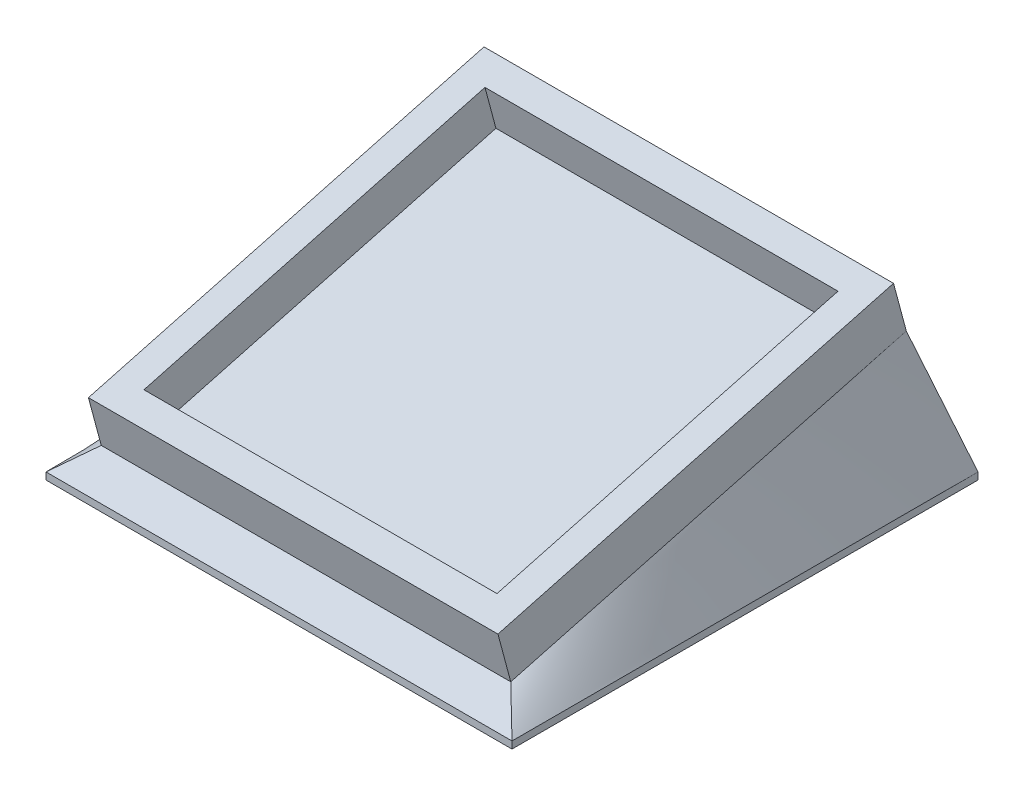
from build123d import *

# Parameters (mm, degrees)
SKETCH1_W             = 36.83
SKETCH1_H             = 36.83
BOSS_EXTRUDE1_DEPTH   = 0.635
SKETCH2_W             = 36.83
SKETCH2_H             = 36.83
SKETCH2_W_2           = 31.75
SKETCH2_H_2           = 31.75
BOSS_EXTRUDE2_DEPTH   = 3.81
SKETCH3_W             = 41.91
SKETCH3_H             = 41.91
BOSS_EXTRUDE3_DEPTH   = 0.635
BODY_MOVE_COPY2_ANGLE = 15
CUT_EXTRUDE1_DEPTH    = 0.635


with BuildPart() as part:
    # Sketch1 → Boss-Extrude1 (new body)
    with BuildSketch(Plane(origin=(0, 0, 0), x_dir=(1, 0, 0), z_dir=(0, 1, 0))):
        with Locations((-3.873751075, -5.413720286)):
            Rectangle(SKETCH1_W, SKETCH1_H)
    extrude(amount=BOSS_EXTRUDE1_DEPTH)

    # Sketch2 → Boss-Extrude2 (add)
    with BuildSketch(Plane(origin=(0, 0.635, 0), x_dir=(1, 0, 0), z_dir=(0, 1, 0))):
        with Locations((-3.873751075, -5.413720286)):
            Rectangle(SKETCH2_W, SKETCH2_H)
        with Locations((-3.873751075, -5.413720286)):
            Rectangle(SKETCH2_W_2, SKETCH2_H_2, mode=Mode.SUBTRACT)
    extrude(amount=BOSS_EXTRUDE2_DEPTH)


with BuildPart() as part_1:
    # Body-Move/Copy1: moved
    add(part.part.moved(Location((0, 7.62, 0))))


with BuildPart() as body_2:
    # Sketch3 → Boss-Extrude3 (new body)
    with BuildSketch(Plane(origin=(0, 0, 0), x_dir=(1, 0, 0), z_dir=(0, 1, 0))):
        with Locations((-3.873751075, -5.413720286)):
            Rectangle(SKETCH3_W, SKETCH3_H)
    extrude(amount=BOSS_EXTRUDE3_DEPTH)


with BuildPart() as part_2:
    # Body-Move/Copy2: moved
    add(part_1.part.rotate(Axis((0, 4.7625, 5.413720286), (1, 0, 0)), BODY_MOVE_COPY2_ANGLE))


    add(body_2.part)  # loft1 joins it to this body
    # loft from a face of the part (loft1)
    loft([part_2.faces().sort_by_distance((-3.873751075, 7.522633049, 6.153295707))[0], part_2.faces().sort_by_distance((-3.873751075, 0.635, 5.413720286))[0]])

    # Sketch4 → Cut-Extrude1 (cut)
    with BuildSketch(Plane(origin=(0, 4.748067122, -14.162331732), x_dir=(-1, 0, 0), z_dir=(0, 0.3178715830785106, -0.9481337757253253))):
        Polygon((-9.954307351, 4.241933762), (-9.307171934, 4.241933762), (-9.307171934, 0.741933762), (-9.621274498, 0.741933762), (-9.621274498, 3.882959403), (-10.159736037, 3.882959403), align=None)
        with BuildLine():
            Line((-5.807171934, 4.241933762), (-5.807171934, 3.882959403))
            Line((-5.807171934, 3.882959403), (-6.997676742, 3.882959403))
            Line((-6.997676742, 3.882959403), (-7.186278505, 2.962386486))
            add(Edge.make_bspline(
                [(-7.186278505, 2.962386486), (-7.14922263, 2.972616758), (-7.077432735, 2.992436292), (-6.971472874, 3.014442062), (-6.87088067, 3.027707506), (-6.8056053, 3.029518817), (-6.774018889, 3.0303953)],
                knots=[0, 0, 0, 0, 1.100273476, 2.13160584, 3.095893838, 4, 4, 4, 4], degree=3))
            add(Edge.make_bspline(
                [(-6.774018889, 3.0303953), (-6.73493515, 3.029549365), (-6.658086752, 3.027886044), (-6.545647805, 3.011914194), (-6.438314912, 2.98677428), (-6.336312542, 2.951653758), (-6.239451991, 2.906744025), (-6.14862443, 2.850644084), (-6.062466517, 2.785110753), (-5.982523923, 2.709765741), (-5.909999615, 2.626844124), (-5.846233625, 2.537686253), (-5.792071035, 2.443158591), (-5.74851028, 2.342357982), (-5.713725946, 2.236398829), (-5.690573951, 2.124166247), (-5.675157242, 2.006718126), (-5.673434856, 1.926413556), (-5.67255655, 1.885463409)],
                knots=[0, 0, 0, 0, 1.052922333, 2.070308379, 3.05430497, 4.020497103, 4.973039431, 5.925935799, 6.892292201, 7.88610001, 8.88166317, 9.857072816, 10.836096531, 11.812156883, 12.81219415, 13.836441305, 14.89672472, 16, 16, 16, 16], degree=3))
            add(Edge.make_bspline(
                [(-5.67255655, 1.885463409), (-5.673221625, 1.856941189), (-5.674542788, 1.800282201), (-5.681261375, 1.716138001), (-5.694197091, 1.633775168), (-5.711564815, 1.553182776), (-5.734107233, 1.474513403), (-5.761396287, 1.397541876), (-5.794792315, 1.322747269), (-5.83142369, 1.249421874), (-5.872670168, 1.179223367), (-5.918448675, 1.11357438), (-5.966814167, 1.051490099), (-6.018855552, 0.993636366), (-6.075056547, 0.940393348), (-6.134736514, 0.891445066), (-6.197419233, 0.845963736), (-6.264074475, 0.805795541), (-6.333216958, 0.768832585), (-6.405845176, 0.738509047), (-6.480305876, 0.711398519), (-6.557670752, 0.689788992), (-6.637764564, 0.672856437), (-6.72071934, 0.661355836), (-6.80610001, 0.652979399), (-6.863975022, 0.652455042), (-6.893209595, 0.652190172)],
                knots=[0, 0, 0, 0, 1.056347294, 2.098418968, 3.122841568, 4.141288669, 5.149314143, 6.15115421, 7.162517403, 8.180376062, 9.185164535, 10.17417709, 11.141909838, 12.097768115, 13.052685741, 14.0056014, 14.954263652, 15.917497458, 16.885230207, 17.854509472, 18.828990115, 19.81800267, 20.826176721, 21.857883937, 22.917946725, 24, 24, 24, 24], degree=3))
            add(Edge.make_bspline(
                [(-6.893209595, 0.652190172), (-6.928083775, 0.65288101), (-6.996694606, 0.654240152), (-7.097215173, 0.668458637), (-7.193929779, 0.688822554), (-7.28605988, 0.719458824), (-7.374431144, 0.757846118), (-7.457853861, 0.80636229), (-7.538459637, 0.861341394), (-7.612971674, 0.926221747), (-7.682127788, 0.997137429), (-7.744034297, 1.07409507), (-7.799167873, 1.155824512), (-7.84664562, 1.242722666), (-7.887143642, 1.334561197), (-7.91895863, 1.431684198), (-7.944636985, 1.533584202), (-7.955500405, 1.603737712), (-7.961018088, 1.639369659)],
                knots=[0, 0, 0, 0, 1.0467383, 2.05933395, 3.04377827, 4.011590433, 4.970194871, 5.932262533, 6.905835911, 7.896367577, 8.894135286, 9.877477877, 10.858688626, 11.851381753, 12.8477658, 13.868841284, 14.917554742, 16, 16, 16, 16], degree=3))
            Line((-7.961018088, 1.639369659), (-7.646915524, 1.639369659))
            add(Edge.make_bspline(
                [(-7.646915524, 1.639369659), (-7.639186967, 1.605993207), (-7.62433225, 1.541841812), (-7.591726502, 1.451710471), (-7.551860626, 1.371391247), (-7.504456278, 1.299821664), (-7.447906247, 1.237412666), (-7.383376818, 1.181795604), (-7.311029095, 1.131620475), (-7.230635865, 1.089797708), (-7.145822786, 1.054128954), (-7.057055576, 1.03037726), (-6.96675123, 1.013676367), (-6.905672859, 1.012004606), (-6.874980428, 1.011164531)],
                knots=[0, 0, 0, 0, 1.136247022, 2.183929868, 3.172523383, 4.106158343, 5.02341133, 5.958108904, 6.928429099, 7.938127109, 8.96079061, 9.975095812, 10.982467395, 12, 12, 12, 12], degree=3))
            add(Edge.make_bspline(
                [(-6.874980428, 1.011164531), (-6.845021984, 1.011985309), (-6.786033561, 1.013601427), (-6.699222175, 1.026040439), (-6.6154093, 1.045198011), (-6.535421944, 1.073867866), (-6.457860404, 1.108712584), (-6.384686634, 1.15342766), (-6.313783757, 1.204887678), (-6.247355623, 1.263844308), (-6.186516174, 1.328814003), (-6.132760053, 1.398291396), (-6.087983139, 1.472408243), (-6.05024903, 1.549881396), (-6.021595731, 1.631559953), (-6.00115475, 1.717061128), (-5.989151691, 1.806596108), (-5.987500511, 1.867665418), (-5.986659114, 1.898784723)],
                knots=[0, 0, 0, 0, 1.027316725, 2.022795036, 3.002884548, 3.971462791, 4.93288096, 5.914575861, 6.907176829, 7.935150275, 8.956128384, 9.956726525, 10.942570165, 11.921478529, 12.907843606, 13.90538589, 14.932640048, 16, 16, 16, 16], degree=3))
            add(Edge.make_bspline(
                [(-5.986659114, 1.898784723), (-5.987317593, 1.926860475), (-5.988606473, 1.981814764), (-5.999137043, 2.06221397), (-6.017454016, 2.138287013), (-6.042877896, 2.210401247), (-6.075157403, 2.278624689), (-6.114603716, 2.343027749), (-6.161957114, 2.402761582), (-6.216049002, 2.457854136), (-6.275307043, 2.508699011), (-6.340750786, 2.552043097), (-6.411010713, 2.588507015), (-6.485240312, 2.619975013), (-6.565205211, 2.642575759), (-6.649321843, 2.659543644), (-6.738498551, 2.669359007), (-6.799469239, 2.670720895), (-6.830809755, 2.671420941)],
                knots=[0, 0, 0, 0, 1.045622112, 2.046656509, 3.013763289, 3.955457236, 4.890082067, 5.820317437, 6.762574623, 7.722996705, 8.69280354, 9.665887285, 10.63943826, 11.638615906, 12.663482002, 13.728887084, 14.832589034, 16, 16, 16, 16], degree=3))
            add(Edge.make_bspline(
                [(-6.830809755, 2.671420941), (-6.857938684, 2.67084035), (-6.913953039, 2.669641577), (-6.999875866, 2.66081508), (-7.090167589, 2.646575785), (-7.184482084, 2.626989538), (-7.283102592, 2.601358461), (-7.385820993, 2.570643961), (-7.49285326, 2.533921962), (-7.564970984, 2.506189748), (-7.602043729, 2.491933762)],
                knots=[0, 0, 0, 0, 0.817624296, 1.688186739, 2.600797293, 3.572016777, 4.590301741, 5.671205678, 6.80286297, 8, 8, 8, 8], degree=3))
            Line((-7.602043729, 2.491933762), (-7.24306937, 4.241933762))
            Line((-7.24306937, 4.241933762), (-5.807171934, 4.241933762))
        make_face()
        Polygon((-3.967428345, 3.299626069), (-3.593730428, 3.299626069), (-2.935377063, 2.376949787), (-2.277023697, 3.299626069), (-1.903325781, 3.299626069), (-2.748177543, 2.115431358), (-1.768710396, 0.741933762), (-2.142408313, 0.741933762), (-2.935377063, 1.853211807), (-3.728345813, 0.741933762), (-4.102043729, 0.741933762), (-3.12187546, 2.115431358), align=None)
        with BuildLine():
            add(Edge.make_bspline(
                [(-0.287941165, 2.490531518), (-0.287613147, 2.546628906), (-0.286975967, 2.65559889), (-0.279887546, 2.814383532), (-0.268112204, 2.963343821), (-0.251974831, 3.102486887), (-0.232336851, 3.231848652), (-0.206121364, 3.351083409), (-0.176308561, 3.460743016), (-0.141756116, 3.561185064), (-0.102768327, 3.653762767), (-0.060334066, 3.740187968), (-0.012769271, 3.820329901), (0.037207641, 3.895467691), (0.091619713, 3.964371386), (0.148918504, 4.028014048), (0.21134038, 4.084924799), (0.276763388, 4.136771101), (0.345779853, 4.182220573), (0.416422519, 4.222253312), (0.489177625, 4.256453179), (0.564243807, 4.283343615), (0.640946365, 4.305554461), (0.719553432, 4.320743409), (0.800194796, 4.330300318), (0.854626231, 4.331213985), (0.882231111, 4.331677352)],
                knots=[0, 0, 0, 0, 1.646270934, 3.197905019, 4.663502075, 6.030701355, 7.308322542, 8.50163776, 9.611534131, 10.641858119, 11.616356847, 12.558055219, 13.465016945, 14.349605745, 15.204443733, 16.039544428, 16.859896111, 17.680448484, 18.487036065, 19.28249412, 20.06191084, 20.843045899, 21.620316918, 22.403196591, 23.190181807, 24, 24, 24, 24], degree=3))
            add(Edge.make_bspline(
                [(0.882231111, 4.331677352), (0.910066589, 4.331189536), (0.965422598, 4.330219425), (1.047262973, 4.320895483), (1.127212655, 4.30542436), (1.204930794, 4.283503385), (1.28105578, 4.256307709), (1.354992188, 4.222220591), (1.427199269, 4.182541724), (1.496529557, 4.135917847), (1.563744172, 4.083935571), (1.627192135, 4.025172902), (1.686879221, 3.960223183), (1.743554526, 3.889781319), (1.795610124, 3.812496234), (1.845183556, 3.729712124), (1.889555592, 3.639981259), (1.932290267, 3.544800791), (1.969177254, 3.441537133), (2.002443499, 3.330772372), (2.029322468, 3.211198185), (2.05171174, 3.08344194), (2.069056636, 2.947034457), (2.081689278, 2.802268141), (2.088362363, 2.64904775), (2.089619064, 2.544289901), (2.090263963, 2.490531518)],
                knots=[0, 0, 0, 0, 0.810914788, 1.612654377, 2.396697861, 3.181598691, 3.963628158, 4.749916497, 5.551656086, 6.361998678, 7.18212741, 8.025565596, 8.878627764, 9.750805457, 10.657531673, 11.591944965, 12.560506719, 13.57287815, 14.630710178, 15.753379473, 16.941251878, 18.199788006, 19.531962791, 20.947069417, 22.433333509, 24, 24, 24, 24], degree=3))
            add(Edge.make_bspline(
                [(2.090263963, 2.490531518), (2.089612379, 2.43700761), (2.088342793, 2.332718458), (2.081764086, 2.180187483), (2.068805455, 2.03618944), (2.052595466, 1.900378977), (2.030144503, 1.773321358), (2.002539337, 1.65457691), (1.971889014, 1.543632838), (1.93405422, 1.441398027), (1.89264351, 1.346446304), (1.847588314, 1.257779156), (1.799318488, 1.174612863), (1.746729743, 1.097613116), (1.690676329, 1.026234459), (1.629958541, 0.961736836), (1.566287956, 0.902566164), (1.49887554, 0.849914537), (1.428463988, 0.803829732), (1.356504912, 0.762615882), (1.281721528, 0.729383187), (1.205808575, 0.700848146), (1.127680209, 0.679047694), (1.047433819, 0.663973838), (0.965477583, 0.65340199), (0.910076018, 0.65259551), (0.882231111, 0.652190172)],
                knots=[0, 0, 0, 0, 1.561518951, 3.042555995, 4.452378317, 5.7783523, 7.031515105, 8.214008947, 9.334062868, 10.386615937, 11.391082383, 12.354592575, 13.286541444, 14.194233754, 15.072674879, 15.931287219, 16.775624067, 17.606195743, 18.42308326, 19.229000347, 20.022332153, 20.807536673, 21.593273796, 22.3848459, 23.188221202, 24, 24, 24, 24], degree=3))
            add(Edge.make_bspline(
                [(0.882231111, 0.652190172), (0.854626997, 0.652656527), (0.800197072, 0.653576089), (0.719544646, 0.663089821), (0.641262203, 0.678385324), (0.564963449, 0.699801928), (0.490256934, 0.726016765), (0.418160647, 0.760170448), (0.347872963, 0.799504517), (0.279581407, 0.844299939), (0.214569246, 0.895621622), (0.152470641, 0.95238591), (0.094845622, 1.016009322), (0.041211526, 1.085487245), (-0.009762562, 1.160180487), (-0.056651935, 1.24110886), (-0.100022789, 1.327951471), (-0.13966628, 1.421269381), (-0.174814943, 1.522424309), (-0.205862652, 1.632573488), (-0.230376809, 1.752689124), (-0.251359764, 1.881806491), (-0.268284147, 2.020480421), (-0.279838473, 2.168786199), (-0.286979788, 2.326631408), (-0.287614858, 2.434901183), (-0.287941165, 2.490531518)],
                knots=[0, 0, 0, 0, 0.810891512, 1.598919785, 2.382837074, 3.152667961, 3.926044502, 4.706494248, 5.493654104, 6.291793342, 7.103789334, 7.925228297, 8.761435821, 9.622817696, 10.50288917, 11.416980706, 12.369136599, 13.353924996, 14.394355917, 15.514179734, 16.714354668, 17.994756427, 19.357759367, 20.818452758, 22.365282078, 24, 24, 24, 24], degree=3))
        make_face()
        with BuildLine():
            add(Edge.make_bspline(
                [(0.026161399, 2.491933762), (0.026280846, 2.445185063), (0.026512669, 2.354455018), (0.03256887, 2.222611757), (0.040819102, 2.099641428), (0.051460399, 1.985387892), (0.067263348, 1.880237879), (0.084970135, 1.783468196), (0.106518225, 1.695590959), (0.132013243, 1.616003149), (0.16105234, 1.54335408), (0.192758204, 1.475752865), (0.226818926, 1.412400928), (0.264938077, 1.35386732), (0.30645314, 1.299961156), (0.350426399, 1.249728324), (0.398498984, 1.204931342), (0.465002726, 1.151204487), (0.552799201, 1.095685354), (0.663419656, 1.047339264), (0.777088107, 1.016956807), (0.854239357, 1.013093051), (0.892747937, 1.011164531)],
                knots=[0, 0, 0, 0, 1.459021318, 2.831673884, 4.118529203, 5.306027144, 6.411944654, 7.436330062, 8.375795394, 9.233974572, 10.042671642, 10.816086306, 11.563610507, 12.285937304, 12.993564865, 13.685989202, 14.367179055, 15.041617293, 16.353048772, 17.594441528, 18.799311195, 20, 20, 20, 20], degree=3))
            add(Edge.make_bspline(
                [(0.892747937, 1.011164531), (0.931505609, 1.012762312), (1.008940932, 1.015954575), (1.122074727, 1.046753312), (1.231904998, 1.093222851), (1.317976938, 1.148170357), (1.383459481, 1.200498686), (1.430376471, 1.245113335), (1.47343852, 1.295069202), (1.514280595, 1.348968498), (1.55173967, 1.407840982), (1.585802808, 1.471403557), (1.616886156, 1.539832735), (1.634595202, 1.587602474), (1.64364938, 1.612025909)],
                knots=[0, 0, 0, 0, 1.353760809, 2.704726607, 4.075137775, 5.516104923, 6.260822281, 7.007110065, 7.778089737, 8.566572457, 9.372053459, 10.217411131, 11.088608312, 12, 12, 12, 12], degree=3))
            add(Edge.make_bspline(
                [(1.64364938, 1.612025909), (1.654201148, 1.643255649), (1.675625761, 1.706665413), (1.703237536, 1.805029065), (1.724982935, 1.908231829), (1.744546301, 2.015656946), (1.757899357, 2.128096647), (1.76864717, 2.245203031), (1.774977857, 2.367064393), (1.775762608, 2.449859384), (1.776161399, 2.491933762)],
                knots=[0, 0, 0, 0, 0.884706709, 1.796334032, 2.740027952, 3.714592787, 4.726048262, 5.777819803, 6.87074269, 8, 8, 8, 8], degree=3))
            add(Edge.make_bspline(
                [(1.776161399, 2.491933762), (1.77561121, 2.534001334), (1.774534922, 2.616294499), (1.770420934, 2.73681268), (1.75979736, 2.851280441), (1.747998241, 2.960190913), (1.73060102, 3.062941216), (1.711843213, 3.160391521), (1.686642001, 3.251334546), (1.659722226, 3.337194128), (1.62891183, 3.416994782), (1.594996096, 3.491108569), (1.558774337, 3.559893293), (1.519432097, 3.623160235), (1.477436414, 3.681192778), (1.431678864, 3.732827372), (1.383974492, 3.779664341), (1.317157306, 3.83312691), (1.229683016, 3.887638605), (1.120837369, 3.937804365), (1.007566724, 3.966612658), (0.93099327, 3.970674345), (0.892747937, 3.972702993)],
                knots=[0, 0, 0, 0, 1.31362396, 2.569729283, 3.763502607, 4.902122613, 5.988968491, 7.01645872, 7.998833611, 8.933434873, 9.825090667, 10.667526885, 11.477055099, 12.250526234, 12.991942729, 13.710640831, 14.402115721, 15.076753259, 16.378508321, 17.609869233, 18.806226677, 20, 20, 20, 20], degree=3))
            add(Edge.make_bspline(
                [(0.892747937, 3.972702993), (0.854037345, 3.970671546), (0.77654564, 3.966604952), (0.662097685, 3.937911698), (0.552393333, 3.887898732), (0.465150359, 3.83294636), (0.398286572, 3.780608048), (0.351203879, 3.735221594), (0.307057707, 3.68557534), (0.266390006, 3.631173425), (0.228300723, 3.572708058), (0.193319711, 3.509719293), (0.161802381, 3.441887929), (0.132717845, 3.369271493), (0.107145057, 3.289690549), (0.086051094, 3.201921555), (0.06656404, 3.105459664), (0.052768772, 2.999740156), (0.040505016, 2.885458002), (0.032623668, 2.762180684), (0.02649241, 2.630116304), (0.026273946, 2.538917145), (0.026161399, 2.491933762)],
                knots=[0, 0, 0, 0, 1.207732386, 2.417664972, 3.655092373, 4.956220595, 5.625982001, 6.301752483, 6.994047911, 7.697131622, 8.419323945, 9.170223765, 9.943494443, 10.752040957, 11.610060368, 12.549350801, 13.567764191, 14.679664412, 15.874934091, 17.154273443, 18.533957287, 20, 20, 20, 20], degree=3))
        make_face(mode=Mode.SUBTRACT)
    extrude(amount=-CUT_EXTRUDE1_DEPTH, mode=Mode.SUBTRACT)


solid = part_2.part
